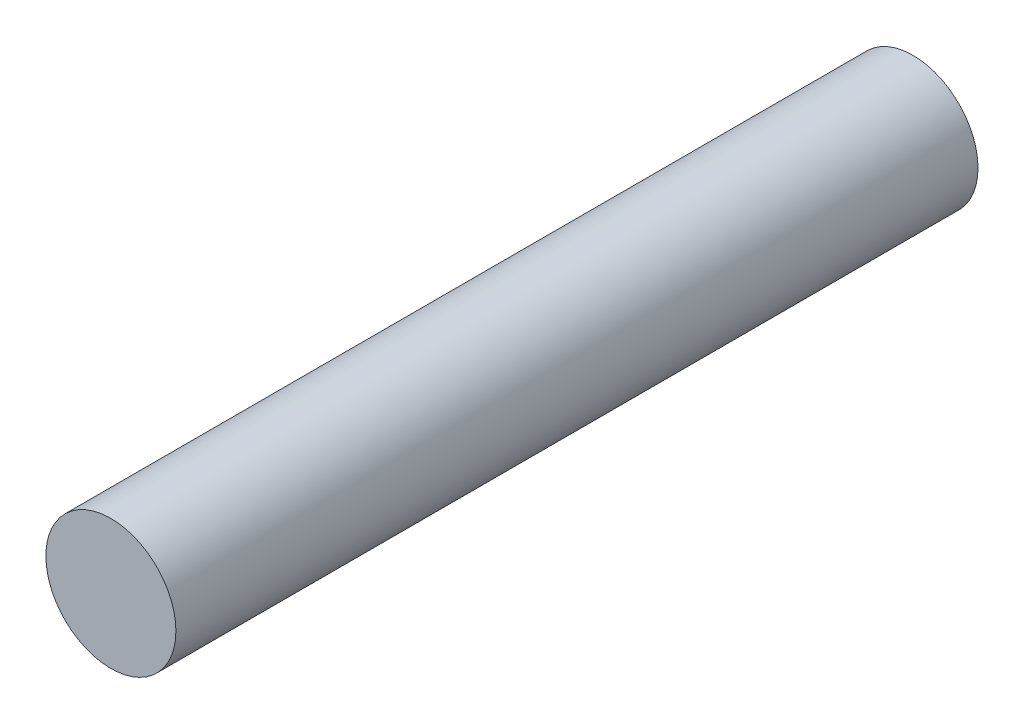
from build123d import *

# Parameters (mm, degrees)
SKETCH1_R      = 0.65
EXTRUDE1_DEPTH = 8.02


with BuildPart() as part:
    # Sketch1 → Extrude1 (new body)
    with BuildSketch(Plane.XY):
        Circle(SKETCH1_R)
    extrude(amount=EXTRUDE1_DEPTH)


solid = part.part
